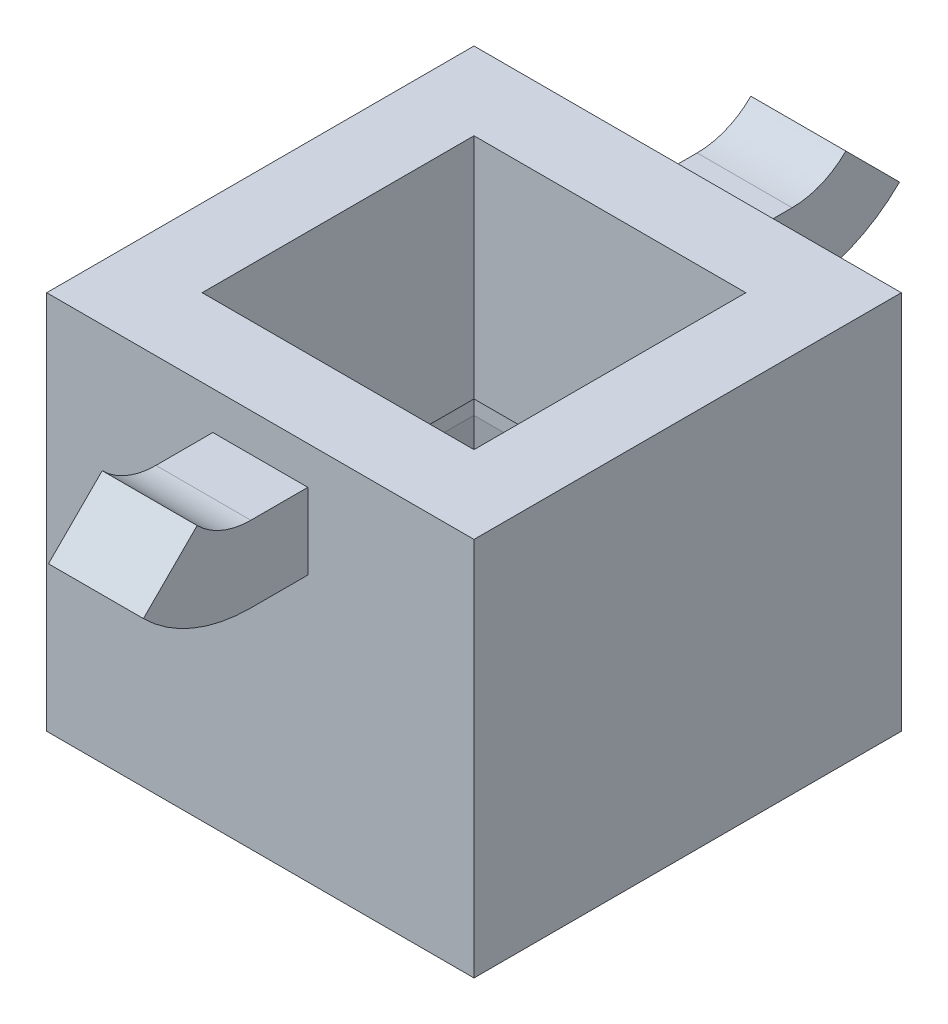
from build123d import *

# Parameters (mm, degrees)
SKETCH1_W           = 22.5
SKETCH1_H           = 22.5
BOSS_EXTRUDE1_DEPTH = 20
SKETCH5_W           = 5
SKETCH5_H           = 4
SKETCH3_W           = 18.5
SKETCH3_H           = 18.5
CUT_EXTRUDE5_DEPTH  = 6
CUT_EXTRUDE5_TAPER  = 8
SKETCH14_W          = 16.813509984
SKETCH14_H          = 16.813509984
CUT_EXTRUDE6_DEPTH  = 2
CUT_EXTRUDE7_REACH  = 14
SKETCH15_W          = 14.313509984
SKETCH15_H          = 14.313509984


with BuildPart() as part:
    # Sketch1 → Boss-Extrude1 (new body)
    with BuildSketch(Plane(origin=(0, 0, 0), x_dir=(1, 0, 0), z_dir=(0, 1, 0))):
        Rectangle(SKETCH1_W, SKETCH1_H)
    extrude(amount=BOSS_EXTRUDE1_DEPTH)

    # Sweep1: sweep along a path in Sketch6
    with BuildLine(Plane(origin=(0, 0, 0), x_dir=(0, 0, -1), z_dir=(1, 0, 0))) as sweep1_path:
        Line((11.25, 16), (14.25, 16))
        ThreePointArc((14.25, 16), (16.546100594, 16.456722805), (18.492640687, 17.757359313))
    # Sketch5 → Sweep1 (sweep)
    with BuildSketch(Plane(origin=(0, 0, -11.25), x_dir=(-1, 0, 0), z_dir=(0, 0, -1))):
        with Locations((0, 16)):
            Rectangle(SKETCH5_W, SKETCH5_H)
    sweep1 = sweep(path=sweep1_path.line)

    # Mirror1: Sweep1 across plane
    add(sweep1.mirror(Plane.XY))

    # Sketch3 → Cut-Extrude5 (cut)
    with BuildSketch(Plane.XZ):
        Rectangle(SKETCH3_W, SKETCH3_H)
    extrude(amount=-CUT_EXTRUDE5_DEPTH, taper=CUT_EXTRUDE5_TAPER, mode=Mode.SUBTRACT)

    # Sketch14 → Cut-Extrude6 (cut)
    with BuildSketch(Plane.XZ.offset(-6)):
        Rectangle(SKETCH14_W, SKETCH14_H)
    extrude(amount=-CUT_EXTRUDE6_DEPTH, mode=Mode.SUBTRACT)

    # Sketch15 → Cut-Extrude7 (cut, up to next)
    with BuildSketch(Plane.XZ.offset(-8), mode=Mode.PRIVATE) as cut_extrude7_sk1:
        Rectangle(SKETCH15_W, SKETCH15_H)
    cut_extrude7_tool1 = extrude(cut_extrude7_sk1.sketch, amount=-CUT_EXTRUDE7_REACH, mode=Mode.PRIVATE) & part.part
    add(cut_extrude7_tool1.solids().sort_by_distance((0, 8, 0))[0], mode=Mode.SUBTRACT)


solid = part.part
